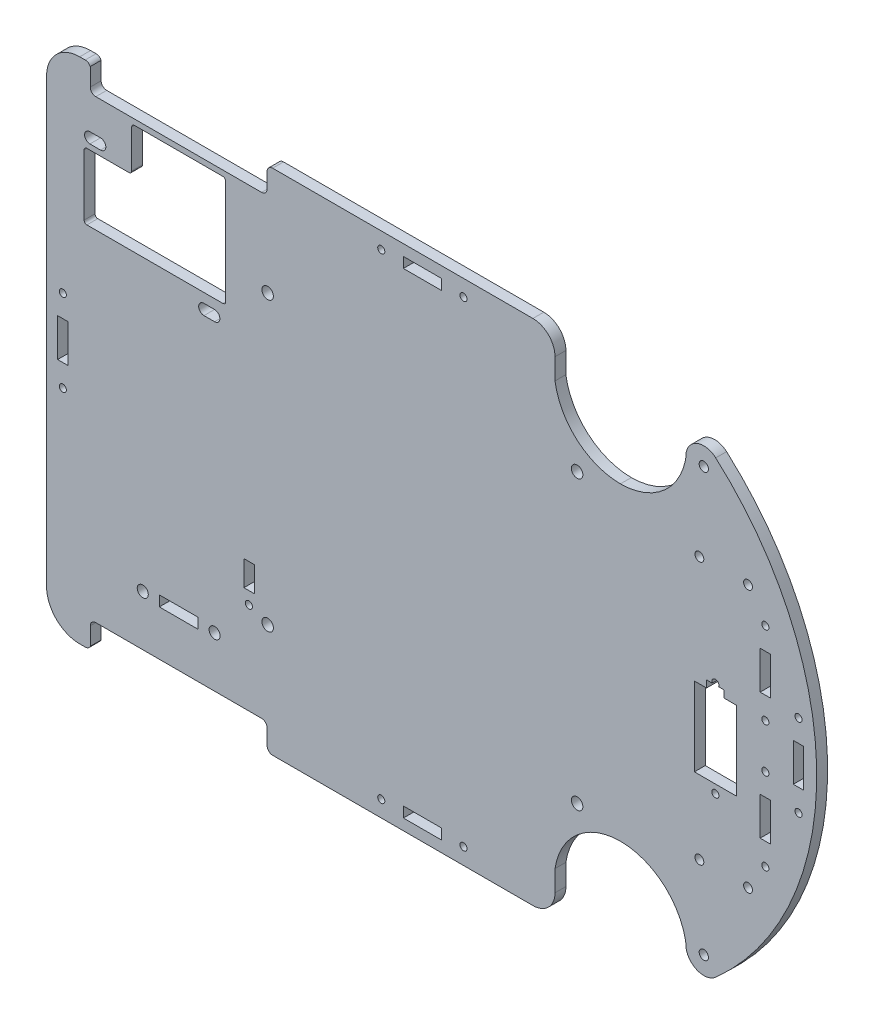
from build123d import *

# Parameters (mm, degrees)
CROQUIS1_W                  = 215.9
CROQUIS1_H                  = 146.05
BI_DEPTH                    = 3.1242
CROQUIS2_R                  = 1.3335
DIRECCION_DEPTH             = 131.36722652
CROQUIS9_R                  = 1.27
SUSPENSION_DEPTH            = 131.36722652
FORMA_DELANTERA_DEPTH       = 131.36722652
DIFERENCIAL_TRASERO_DEPTH   = 131.36722652
ENTRADA_TRANSMISION_DEPTH   = 131.36722652
CROQUIS10_R                 = 1.016
CROQUIS10_W                 = 12.065
CROQUIS10_H                 = 22.606
CROQUIS10_W_2               = 5.08
CROQUIS10_H_2               = 2.032
SERVO_DEPTH                 = 131.36722652
CROQUIS12_R                 = 1.651
SOPORTES_BS_DEPTH           = 131.36722652
CROQUIS7_R                  = 1.5875
CROQUIS7_W                  = 11.1125
CROQUIS7_H                  = 2.9972
SOPORTE_EJE_DEPTH           = 131.36722652
CROQUIS14_R                 = 1.016
CROQUIS14_W                 = 2.9972
CROQUIS14_H                 = 7.239
ENCODER_DEPTH               = 131.36722652
SALIENTE_EXTRUIR1_DEPTH     = 3.1242
CROQUIS13_R                 = 1.016
CROQUIS13_W                 = 2.9972
CROQUIS13_H                 = 10.922
CROQUIS13_W_2               = 10.922
CROQUIS13_H_2               = 2.9972
SENSORES_DE_PRESENCIA_DEPTH = 135.807879643


with BuildPart() as part:
    # Croquis1 → BI (new body)
    with BuildSketch(Plane.XY):
        Rectangle(CROQUIS1_W, CROQUIS1_H)
    extrude(amount=BI_DEPTH)

    # Croquis2 → Direccion (cut, through all)
    with BuildSketch(Plane.XY.offset(3.1242)):
        with BuildLine():
            ThreePointArc((82.1674125, 60.7314), (81.516352882, 61.877042778), (80.1989125, 61.904002767))
            Line((80.1989125, 61.904002767), (80.1989125, 59.558797233))
            ThreePointArc((80.1989125, 59.558797233), (81.516352882, 59.585757222), (82.1674125, 60.7314))
        make_face()
        with BuildLine():
            Line((80.1989125, 59.558797233), (80.1989125, 61.904002767))
            ThreePointArc((80.1989125, 61.904002767), (79.5004125, 60.7314), (80.1989125, 59.558797233))
        make_face()
        with Locations(Location((80.8339125, -60.7314, 0), (0, 0, 180))):
            Circle(CROQUIS2_R)
    extrude(amount=-DIRECCION_DEPTH, mode=Mode.SUBTRACT)

    # Croquis9 → Suspension (cut, through all)
    with BuildSketch(Plane.XY.offset(3.1242)):
        with Locations((93.5339125, 37.6809)):
            Circle(CROQUIS9_R)
        with Locations(Location((93.5339125, -37.6809, 0), (0, 0, 180))):
            Circle(CROQUIS9_R)
        with Locations((79.5639125, 37.6809)):
            Circle(CROQUIS9_R)
        with Locations((79.5639125, -37.6809)):
            Circle(CROQUIS9_R)
    extrude(amount=-SUSPENSION_DEPTH, mode=Mode.SUBTRACT)

    # Croquis3 → Forma delantera (cut, through all)
    with BuildSketch(Plane.XY.offset(3.1242)):
        with BuildLine():
            ThreePointArc((31.75, 73.025), (36.240128061, 71.165128061), (38.1, 66.675))
            Line((38.1, 66.675), (38.1, 60.648925294))
            ThreePointArc((38.1, 60.648925294), (44.483976367, 49.058906773), (56.88726875, 44.45))
            ThreePointArc((56.88726875, 44.45), (68.952768587, 48.752886462), (75.572740263, 59.719521917))
            ThreePointArc((75.572740263, 59.719521917), (75.649024122, 60.222907145), (75.6745375, 60.7314))
            ThreePointArc((75.6745375, 60.7314), (79.079726884, 65.583408163), (84.800442563, 64.030762007))
            ThreePointArc((84.800442563, 64.030762007), (101.984927744, 34.043503392), (107.95, 0))
            Line((107.95, 0), (107.95, 73.025))
            Line((107.95, 73.025), (31.75, 73.025))
        make_face()
        with BuildLine():
            Line((107.95, -73.025), (107.95, 0))
            ThreePointArc((107.95, 0), (101.984927744, -34.043503392), (84.800442563, -64.030762007))
            ThreePointArc((84.800442563, -64.030762007), (79.079726884, -65.583408163), (75.6745375, -60.7314))
            ThreePointArc((75.6745375, -60.7314), (75.649024122, -60.222907145), (75.572740263, -59.719521917))
            ThreePointArc((75.572740263, -59.719521917), (68.952768587, -48.752886462), (56.88726875, -44.45))
            ThreePointArc((56.88726875, -44.45), (44.483976367, -49.058906773), (38.1, -60.648925294))
            Line((38.1, -60.648925294), (38.1, -66.675))
            ThreePointArc((38.1, -66.675), (36.240128061, -71.165128061), (31.75, -73.025))
            Line((31.75, -73.025), (107.95, -73.025))
        make_face()
        with BuildLine():
            ThreePointArc((-107.95, 63.5), (-105.160192091, 70.235192091), (-98.425, 73.025))
            Line((-98.425, 73.025), (-107.95, 73.025))
            Line((-107.95, 73.025), (-107.95, 63.5))
        make_face()
        with BuildLine():
            Line((-107.95, -73.025), (-98.425, -73.025))
            ThreePointArc((-98.425, -73.025), (-105.160192091, -70.235192091), (-107.95, -63.5))
            Line((-107.95, -63.5), (-107.95, -73.025))
        make_face()
    extrude(amount=-FORMA_DELANTERA_DEPTH, mode=Mode.SUBTRACT)

    # Croquis8 → Diferencial trasero (cut, through all)
    with BuildSketch(Plane.XY.offset(3.1242)):
        with BuildLine():
            Line((-62.738, 29.5402), (-59.69, 29.5402))
            ThreePointArc((-59.69, 29.5402), (-58.166, 28.0162), (-59.69, 26.4922))
            Line((-59.69, 26.4922), (-62.738, 26.4922))
            ThreePointArc((-62.738, 26.4922), (-64.262, 28.0162), (-62.738, 29.5402))
        make_face()
        with BuildLine():
            Line((-95.504, 55.8546), (-92.456, 55.8546))
            ThreePointArc((-92.456, 55.8546), (-90.932, 54.3306), (-92.456, 52.8066))
            Line((-92.456, 52.8066), (-95.504, 52.8066))
            ThreePointArc((-95.504, 52.8066), (-97.028, 54.3306), (-95.504, 55.8546))
        make_face()
    extrude(amount=-DIFERENCIAL_TRASERO_DEPTH, mode=Mode.SUBTRACT)

    # Croquis11 → Entrada transmision (cut, through all)
    with BuildSketch(Plane.XY.offset(3.1242)):
        with BuildLine():
            ThreePointArc((-96.8375, 73.025), (-95.984195865, 72.776166614), (-95.398394794, 72.107673453))
            Line((-95.398394794, 72.107673453), (-95.398394794, 67.0052))
            ThreePointArc((-95.398394794, 67.0052), (-94.93342681, 65.882667985), (-93.810894794, 65.4177))
            Line((-93.810894794, 65.4177), (-46.185894794, 65.4177))
            ThreePointArc((-46.185894794, 65.4177), (-45.063362779, 65.882667985), (-44.598394794, 67.0052))
            Line((-44.598394794, 67.0052), (-44.598394794, 71.4375))
            ThreePointArc((-44.598394794, 71.4375), (-44.13342681, 72.560032015), (-43.010894794, 73.025))
            Line((-43.010894794, 73.025), (-96.8375, 73.025))
        make_face()
        with BuildLine():
            Line((-96.8375, -73.025), (-43.010894794, -73.025))
            ThreePointArc((-43.010894794, -73.025), (-44.13342681, -72.560032015), (-44.598394794, -71.4375))
            Line((-44.598394794, -71.4375), (-44.598394794, -67.0052))
            ThreePointArc((-44.598394794, -67.0052), (-45.063362779, -65.882667985), (-46.185894794, -65.4177))
            Line((-46.185894794, -65.4177), (-93.810894794, -65.4177))
            ThreePointArc((-93.810894794, -65.4177), (-94.93342681, -65.882667985), (-95.398394794, -67.0052))
            Line((-95.398394794, -67.0052), (-95.398394794, -72.107673453))
            ThreePointArc((-95.398394794, -72.107673453), (-95.984195865, -72.776166614), (-96.8375, -73.025))
        make_face()
        with BuildLine():
            Line((-57.298394794, 63.8302), (-82.698394794, 63.8302))
            ThreePointArc((-82.698394794, 63.8302), (-83.259660802, 63.597716008), (-83.492144794, 63.03645))
            Line((-83.492144794, 63.03645), (-83.492144794, 52.0827))
            ThreePointArc((-83.492144794, 52.0827), (-83.724628787, 51.521433992), (-84.285894794, 51.28895))
            Line((-84.285894794, 51.28895), (-96.36125, 51.28895))
            ThreePointArc((-96.36125, 51.28895), (-96.922516008, 51.056466008), (-97.155, 50.4952))
            Line((-97.155, 50.4952), (-97.155, 33.0327))
            ThreePointArc((-97.155, 33.0327), (-96.922516008, 32.471433992), (-96.36125, 32.23895))
            Line((-96.36125, 32.23895), (-57.298394794, 32.23895))
            ThreePointArc((-57.298394794, 32.23895), (-56.737128787, 32.471433992), (-56.504644794, 33.0327))
            Line((-56.504644794, 33.0327), (-56.504644794, 63.03645))
            ThreePointArc((-56.504644794, 63.03645), (-56.737128787, 63.597716008), (-57.298394794, 63.8302))
        make_face()
    extrude(amount=-ENTRADA_TRANSMISION_DEPTH, mode=Mode.SUBTRACT)

    # Croquis10 → Servo (cut, through all)
    with BuildSketch(Plane.XY.offset(3.1242)):
        with Locations((84.1629, 8.46074)):
            Circle(CROQUIS10_R)
        with Locations((84.1629, -19.00174)):
            Circle(CROQUIS10_R)
        with Locations((84.1629, -5.2705)):
            Rectangle(CROQUIS10_W, CROQUIS10_H)
        with Locations((84.1629, 7.0485)):
            Rectangle(CROQUIS10_W_2, CROQUIS10_H_2)
    extrude(amount=-SERVO_DEPTH, mode=Mode.SUBTRACT)

    # Croquis12 → Soportes BS (cut, through all)
    with BuildSketch(Plane.XY.offset(3.1242)):
        with Locations((44.45, 41.275)):
            Circle(CROQUIS12_R)
        with Locations((-44.45, 41.275)):
            Circle(CROQUIS12_R)
        with Locations((-44.45, -41.275)):
            Circle(CROQUIS12_R)
        with Locations((44.45, -41.275)):
            Circle(CROQUIS12_R)
    extrude(amount=-SOPORTES_BS_DEPTH, mode=Mode.SUBTRACT)

    # Croquis7 → Soporte eje (cut, through all)
    with BuildSketch(Plane.XY.offset(3.1242)):
        with Locations((-80.317144794, -50.8889)):
            Circle(CROQUIS7_R)
        with Locations((-59.679644794, -50.8889)):
            Circle(CROQUIS7_R)
        with Locations((-69.998394794, -50.8889)):
            Rectangle(CROQUIS7_W, CROQUIS7_H)
    extrude(amount=-SOPORTE_EJE_DEPTH, mode=Mode.SUBTRACT)

    # Croquis14 → Encoder (cut, through all)
    with BuildSketch(Plane.XY.offset(3.1242)):
        with Locations((-49.843494794, -39.0144)):
            Circle(CROQUIS14_R)
        with Locations((-49.767294794, -31.8389)):
            Rectangle(CROQUIS14_W, CROQUIS14_H)
    extrude(amount=-ENCODER_DEPTH, mode=Mode.SUBTRACT)

    # Croquis15 → Saliente-Extruir1 (add)
    with BuildSketch(Plane.XY.offset(3.1242)):
        with BuildLine():
            ThreePointArc((84.26085204, 64.588242722), (84.541141165, 64.319659468), (84.800442563, 64.030762007))
            ThreePointArc((84.800442563, 64.030762007), (107.95, 0), (84.800442563, -64.030762007))
            ThreePointArc((84.800442563, -64.030762007), (84.541141165, -64.319659468), (84.26085204, -64.588242722))
            ThreePointArc((84.26085204, -64.588242722), (113.272914517, 0), (84.26085204, 64.588242722))
        make_face()
    extrude(amount=-SALIENTE_EXTRUIR1_DEPTH)

    # Croquis13 → Sensores de presencia (cut, through all)
    with BuildSketch(Plane.XY.offset(3.1242)):
        with Locations((108.0389, 11.811)):
            Circle(CROQUIS13_R)
        with Locations(Location((108.0389, -11.811, 0), (0, 0, 180))):
            Circle(CROQUIS13_R)
        with Locations((11.811, 68.3514)):
            Circle(CROQUIS13_R)
        with Locations((-11.811, 68.3514)):
            Circle(CROQUIS13_R)
        with Locations(Location((-11.811, -68.3514, 0), (0, 0, 180))):
            Circle(CROQUIS13_R)
        with Locations(Location((11.811, -68.3514, 0), (0, 0, 180))):
            Circle(CROQUIS13_R)
        with Locations((98.5139, 29.972)):
            Circle(CROQUIS13_R)
        with Locations(Location((98.5139, 6.35, 0), (0, 0, 180))):
            Circle(CROQUIS13_R)
        with Locations((98.5139, -6.35)):
            Circle(CROQUIS13_R)
        with Locations(Location((98.5139, -29.972, 0), (0, 0, 180))):
            Circle(CROQUIS13_R)
        with Locations((-103.2764, 11.811)):
            Circle(CROQUIS13_R)
        with Locations((-103.2764, -11.811)):
            Circle(CROQUIS13_R)
        with Locations((108.0389, 0)):
            Rectangle(CROQUIS13_W, CROQUIS13_H)
        with Locations((0, 68.3514)):
            Rectangle(CROQUIS13_W_2, CROQUIS13_H_2)
        with Locations((0, -68.3514)):
            Rectangle(CROQUIS13_W_2, CROQUIS13_H_2)
        with Locations((98.5139, 18.161)):
            Rectangle(CROQUIS13_W, CROQUIS13_H)
        with Locations((98.5139, -18.161)):
            Rectangle(CROQUIS13_W, CROQUIS13_H)
        with Locations((-103.2764, 0)):
            Rectangle(CROQUIS13_W, CROQUIS13_H)
    extrude(amount=-SENSORES_DE_PRESENCIA_DEPTH, mode=Mode.SUBTRACT)


solid = part.part
